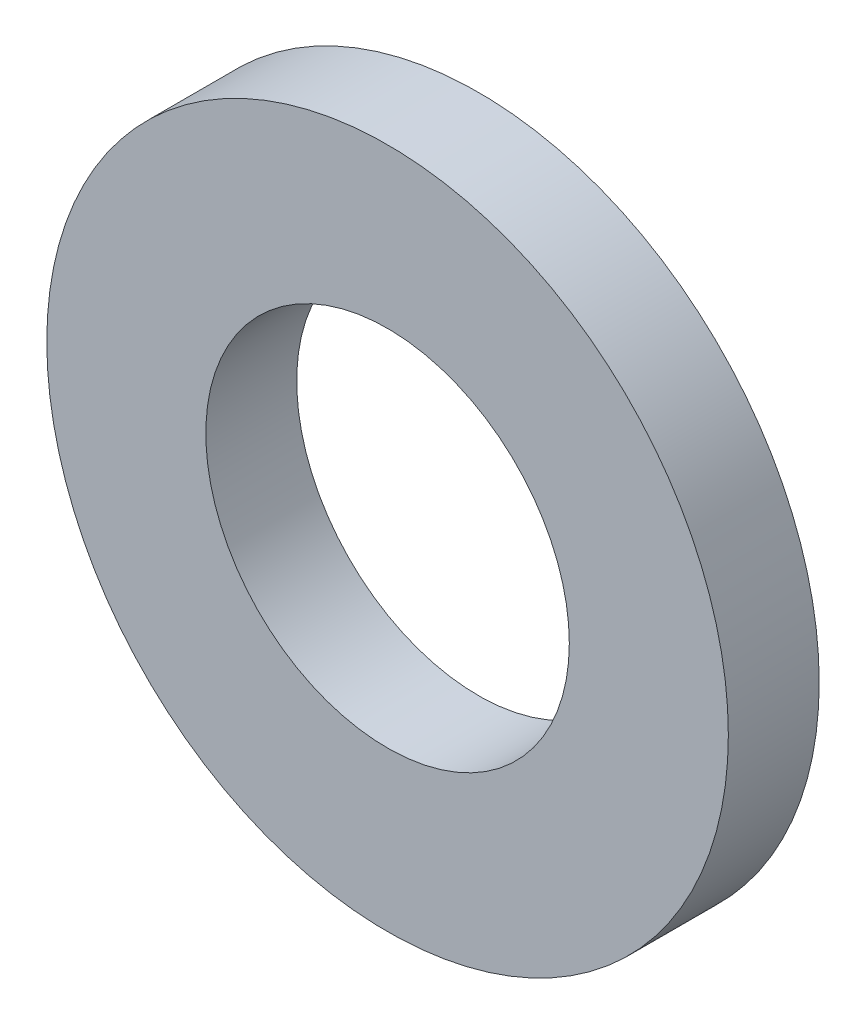
from build123d import *

# Parameters (mm, degrees)
CROQUIS1_R              = 6
CROQUIS1_R_2            = 3.2
SALIENTE_EXTRUIR1_DEPTH = 0.8


with BuildPart() as part:
    # Croquis1 → Saliente-Extruir1 (new body, symmetric)
    with BuildSketch(Plane.XY):
        Circle(CROQUIS1_R)
        Circle(CROQUIS1_R_2, mode=Mode.SUBTRACT)
    extrude(amount=SALIENTE_EXTRUIR1_DEPTH, both=True)


solid = part.part
